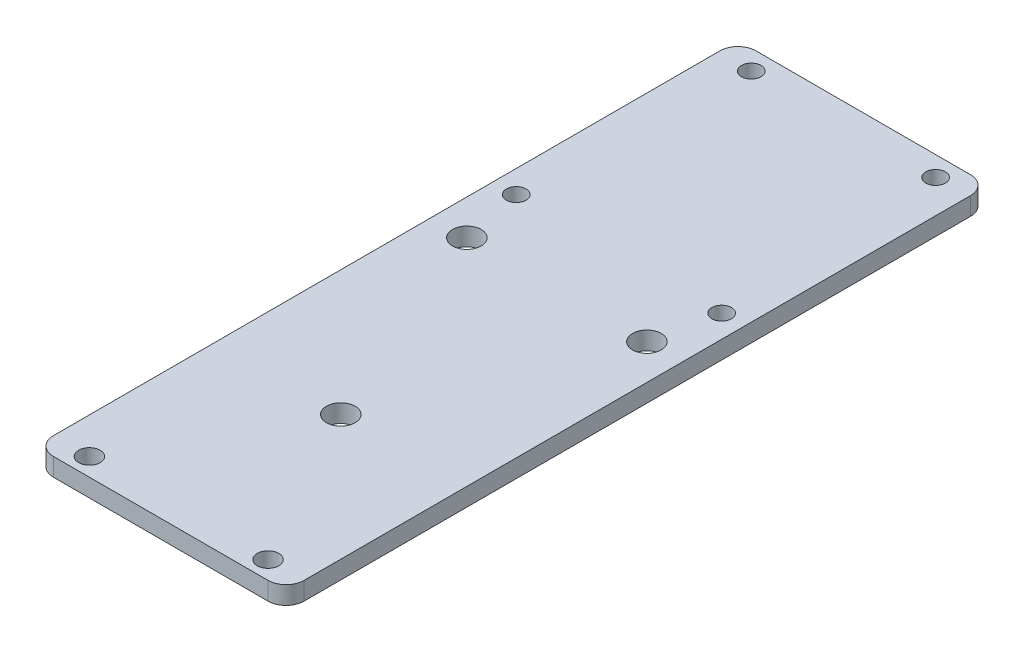
from build123d import *

# Parameters (mm, degrees)
SKETCH1_W                  = 44.2
SKETCH1_H                  = 123.88
BOSS_EXTRUDE1_DEPTH        = 3.175
F_5_CLEARANCE_HOLE1_D      = 3.4544
F_6_CLEARANCE_HOLE1_D      = 3.7973
FILLET1_R                  = 3.175
F_8_0_199_DIAMETER_HOLE1_D = 5.0546


with BuildPart() as part:
    # Sketch1 → Boss-Extrude1 (new body)
    with BuildSketch(Plane(origin=(0, 0, 0), x_dir=(1, 0, 0), z_dir=(0, 1, 0))):
        with Locations((-12.725, -38.594662694)):
            Rectangle(SKETCH1_W, SKETCH1_H)
    extrude(amount=BOSS_EXTRUDE1_DEPTH)

    # #5 Clearance Hole1 (through all)
    with Locations(Plane(origin=(0, 0, 0), x_dir=(-1, 0, 0), z_dir=(0, -1, 0))):
        with Locations((28.975, 19.845337306), (-3.525, 19.845337306), (-5.3852, -19.737862694), (30.8352, -19.737862694)):
            Hole(F_5_CLEARANCE_HOLE1_D / 2)

    # #6 Clearance Hole1 (through all)
    with Locations(Plane(origin=(0, 3.175, 0), x_dir=(1, 0, 0), z_dir=(0, 1, 0))):
        with Locations((3.025, -97.359662694), (-28.475, -97.359662694)):
            Hole(F_6_CLEARANCE_HOLE1_D / 2)

    # Fillet1
    fillet1_edges = [part.edges().sort_by_distance(p)[0] for p in [
        (-34.825, 1.5875, -23.345337306),
        (9.375, 1.5875, -23.345337306),
        (9.375, 1.5875, 100.534662694),
        (-34.825, 1.5875, 100.534662694),
    ]]
    fillet(fillet1_edges, radius=FILLET1_R)

    # #8 (0.199) Diameter Hole1 (through all)
    with Locations(Plane(origin=(0, 0, 0), x_dir=(-1, 0, 0), z_dir=(0, -1, 0))):
        with Locations((-3.15, -30.684662694), (28.6, -30.684662694), (12.725, -68.784662694)):
            Hole(F_8_0_199_DIAMETER_HOLE1_D / 2)


solid = part.part
